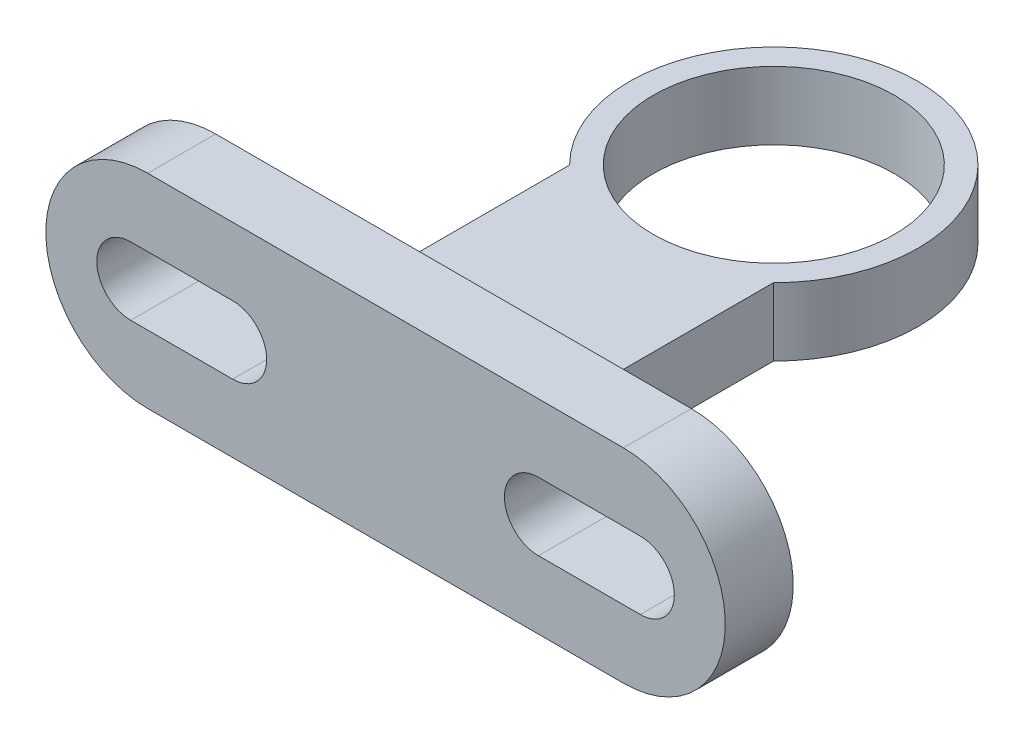
from build123d import *

# Parameters (mm, degrees)
SKETCH1_R           = 42.5
SKETCH1_R_2         = 35.5
BOSS_EXTRUDE3_DEPTH = 20
BOSS_EXTRUDE4_DEPTH = 20
BOSS_EXTRUDE6_DEPTH = 20


with BuildPart() as part:
    # Sketch1 → Boss-Extrude3 (new body)
    with BuildSketch(Plane(origin=(0, 0, 0), x_dir=(1, 0, 0), z_dir=(0, 1, 0))):
        Circle(SKETCH1_R)
        Circle(SKETCH1_R_2, mode=Mode.SUBTRACT)
    extrude(amount=BOSS_EXTRUDE3_DEPTH)

    # Sketch5 → Boss-Extrude4 (add)
    with BuildSketch(Plane(origin=(0, 0, 0), x_dir=(1, 0, 0), z_dir=(0, 1, 0))):
        with BuildLine():
            Line((-30, -94.285), (30, -94.285))
            Line((30, -94.285), (30, -30.103986447))
            ThreePointArc((30, -30.103986447), (0, -42.5), (-30, -30.103986447))
            Line((-30, -30.103986447), (-30, -94.285))
        make_face()
    extrude(amount=BOSS_EXTRUDE4_DEPTH)

    # Sketch6 → Boss-Extrude6 (add)
    with BuildSketch(Plane.XY.offset(94.285)):
        with BuildLine():
            Line((70, -20), (-70, -20))
            ThreePointArc((-70, -20), (-100, 10), (-70, 40))
            Line((-70, 40), (70, 40))
            ThreePointArc((70, 40), (100, 10), (70, -20))
        make_face()
        with BuildLine():
            Line((-45, 0), (-75, 0))
            ThreePointArc((-75, 0), (-85, 10), (-75, 20))
            Line((-75, 20), (-45, 20))
            ThreePointArc((-45, 20), (-35, 10), (-45, 0))
        make_face(mode=Mode.SUBTRACT)
        with BuildLine():
            Line((45, 0), (75, 0))
            ThreePointArc((75, 0), (85, 10), (75, 20))
            Line((75, 20), (45, 20))
            ThreePointArc((45, 20), (35, 10), (45, 0))
        make_face(mode=Mode.SUBTRACT)
    extrude(amount=BOSS_EXTRUDE6_DEPTH)


solid = part.part
